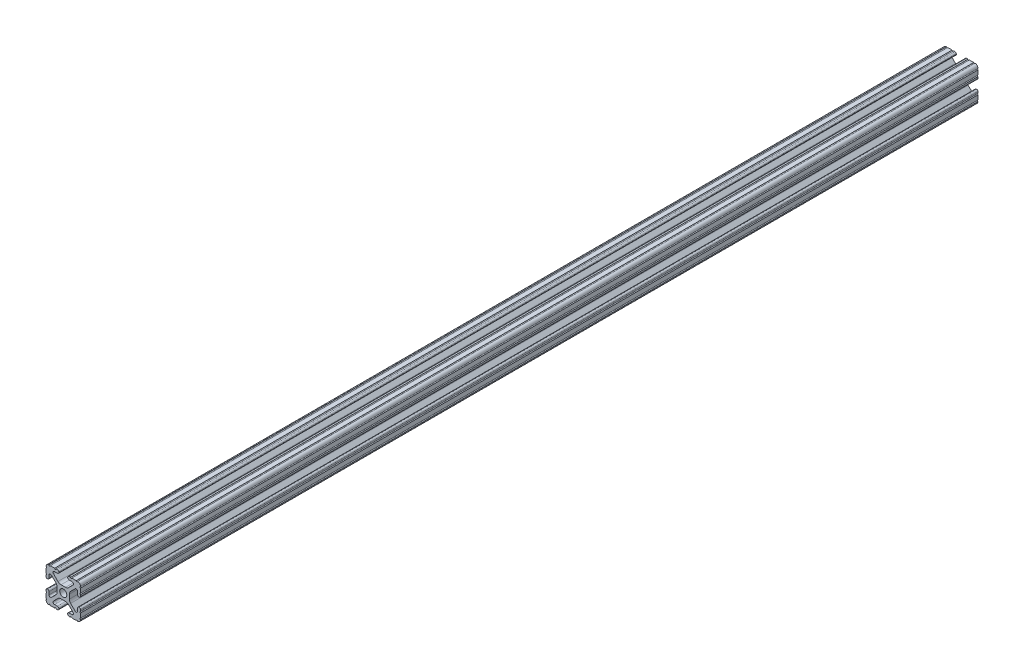
from build123d import *

# Parameters (mm, degrees)
SKETCH1_R               = 2.6035
BOSS_EXTRUDE1_DEPTH     = 457.2
CUT_EXTRUDE2_DEPTH      = 4.318
CUT_EXTRUDE2_DEPTH_BACK = 26.924


with BuildPart() as part:
    # Sketch1 → Boss-Extrude1 (new body, symmetric)
    with BuildSketch(Plane.XY):
        with BuildLine():
            Line((-7.179650497, -8.645192506), (-3.952270251, -5.423690499))
            ThreePointArc((-3.952270251, -5.423690499), (-2.922936451, -4.736929036), (-1.709253557, -4.4958))
            Line((-1.709253557, -4.4958), (1.709253557, -4.4958))
            ThreePointArc((1.709253557, -4.4958), (2.922936451, -4.736929036), (3.952270251, -5.423690499))
            Line((3.952270251, -5.423690499), (7.179650497, -8.645192506))
            ThreePointArc((7.179650497, -8.645192506), (7.41473083, -9.822813117), (6.416408329, -10.4902))
            Line((6.416408329, -10.4902), (4.287512407, -10.4902))
            ThreePointArc((4.287512407, -10.4902), (3.54574862, -10.79744862), (3.2385, -11.539212407))
            Line((3.2385, -11.539212407), (3.2385, -11.650987593))
            ThreePointArc((3.2385, -11.650987593), (3.54574862, -12.39275138), (4.287512407, -12.7))
            Line((4.287512407, -12.7), (5.317126718, -12.7))
            ThreePointArc((5.317126718, -12.7), (5.825126718, -12.192), (6.333126718, -12.7))
            Line((6.333126718, -12.7), (9.550443118, -12.7))
            ThreePointArc((9.550443118, -12.7), (10.058366869, -12.192000006), (10.566443095, -12.699847501))
            ThreePointArc((10.566443095, -12.699847501), (12.082537762, -12.08250727), (12.699846982, -10.566399977))
            ThreePointArc((12.699846982, -10.566399977), (12.192000006, -10.058323491), (12.7, -9.5504))
            Line((12.7, -9.5504), (12.7, -6.3330836))
            ThreePointArc((12.7, -6.3330836), (12.192, -5.8250836), (12.7, -5.3170836))
            Line((12.7, -5.3170836), (12.7, -4.287469289))
            ThreePointArc((12.7, -4.287469289), (12.39275138, -3.545705502), (11.650987593, -3.238456882))
            Line((11.650987593, -3.238456882), (11.539212407, -3.238456882))
            ThreePointArc((11.539212407, -3.238456882), (10.79744862, -3.545705502), (10.4902, -4.287469289))
            Line((10.4902, -4.287469289), (10.4902, -6.402089023))
            ThreePointArc((10.4902, -6.402089023), (9.856505071, -7.351067942), (8.737131347, -7.129408934))
            Line((8.737131347, -7.129408934), (5.441005833, -3.840816462))
            ThreePointArc((5.441005833, -3.840816462), (4.750877967, -2.809883091), (4.5085, -1.593185507))
            Line((4.5085, -1.593185507), (4.5085, 1.593185507))
            ThreePointArc((4.5085, 1.593185507), (4.750877967, 2.809883091), (5.441005833, 3.840816462))
            Line((5.441005833, 3.840816462), (8.737131347, 7.129408934))
            ThreePointArc((8.737131347, 7.129408934), (9.856505071, 7.351067942), (10.4902, 6.402089023))
            Line((10.4902, 6.402089023), (10.4902, 4.287469289))
            ThreePointArc((10.4902, 4.287469289), (10.79744862, 3.545705502), (11.539212407, 3.238456882))
            Line((11.539212407, 3.238456882), (11.650987593, 3.238456882))
            ThreePointArc((11.650987593, 3.238456882), (12.39275138, 3.545705502), (12.7, 4.287469289))
            Line((12.7, 4.287469289), (12.7, 5.3170836))
            ThreePointArc((12.7, 5.3170836), (12.192, 5.8250836), (12.7, 6.3330836))
            Line((12.7, 6.3330836), (12.7, 9.5504))
            ThreePointArc((12.7, 9.5504), (12.192000006, 10.058323491), (12.699846982, 10.566399977))
            ThreePointArc((12.699846982, 10.566399977), (12.082537762, 12.08250727), (10.566443095, 12.699847501))
            ThreePointArc((10.566443095, 12.699847501), (10.058366869, 12.192000006), (9.550443118, 12.7))
            Line((9.550443118, 12.7), (6.333126718, 12.7))
            ThreePointArc((6.333126718, 12.7), (5.825126718, 12.192), (5.317126718, 12.7))
            Line((5.317126718, 12.7), (4.287512407, 12.7))
            ThreePointArc((4.287512407, 12.7), (3.54574862, 12.39275138), (3.2385, 11.650987593))
            Line((3.2385, 11.650987593), (3.2385, 11.539212407))
            ThreePointArc((3.2385, 11.539212407), (3.54574862, 10.79744862), (4.287512407, 10.4902))
            Line((4.287512407, 10.4902), (6.476788598, 10.4902))
            ThreePointArc((6.476788598, 10.4902), (7.432222385, 9.85140422), (7.207036008, 8.724370562))
            Line((7.207036008, 8.724370562), (3.898272566, 5.423169045))
            ThreePointArc((3.898272566, 5.423169045), (2.869120213, 4.736787962), (1.655778399, 4.4958))
            Line((1.655778399, 4.4958), (-1.655778399, 4.4958))
            ThreePointArc((-1.655778399, 4.4958), (-2.869120213, 4.736787962), (-3.898272566, 5.423169045))
            Line((-3.898272566, 5.423169045), (-7.207036008, 8.724370562))
            ThreePointArc((-7.207036008, 8.724370562), (-7.432222385, 9.85140422), (-6.476788598, 10.4902))
            Line((-6.476788598, 10.4902), (-4.287512407, 10.4902))
            ThreePointArc((-4.287512407, 10.4902), (-3.54574862, 10.79744862), (-3.2385, 11.539212407))
            Line((-3.2385, 11.539212407), (-3.2385, 11.650987593))
            ThreePointArc((-3.2385, 11.650987593), (-3.54574862, 12.39275138), (-4.287512407, 12.7))
            Line((-4.287512407, 12.7), (-5.317126718, 12.7))
            ThreePointArc((-5.317126718, 12.7), (-5.825126718, 12.192), (-6.333126718, 12.7))
            Line((-6.333126718, 12.7), (-9.550443118, 12.7))
            ThreePointArc((-9.550443118, 12.7), (-10.058366869, 12.192000006), (-10.566443095, 12.699847501))
            ThreePointArc((-10.566443095, 12.699847501), (-12.082537762, 12.08250727), (-12.699846982, 10.566399977))
            ThreePointArc((-12.699846982, 10.566399977), (-12.192000006, 10.058323491), (-12.7, 9.5504))
            Line((-12.7, 9.5504), (-12.7, 6.3330836))
            ThreePointArc((-12.7, 6.3330836), (-12.192, 5.8250836), (-12.7, 5.3170836))
            Line((-12.7, 5.3170836), (-12.7, 4.287469289))
            ThreePointArc((-12.7, 4.287469289), (-12.39275138, 3.545705502), (-11.650987593, 3.238456882))
            Line((-11.650987593, 3.238456882), (-11.539212407, 3.238456882))
            ThreePointArc((-11.539212407, 3.238456882), (-10.79744862, 3.545705502), (-10.4902, 4.287469289))
            Line((-10.4902, 4.287469289), (-10.4902, 6.402089023))
            ThreePointArc((-10.4902, 6.402089023), (-9.856505071, 7.351067942), (-8.737131347, 7.129408934))
            Line((-8.737131347, 7.129408934), (-5.441005833, 3.840816462))
            ThreePointArc((-5.441005833, 3.840816462), (-4.750877967, 2.809883091), (-4.5085, 1.593185507))
            Line((-4.5085, 1.593185507), (-4.5085, -1.593185507))
            ThreePointArc((-4.5085, -1.593185507), (-4.750877967, -2.809883091), (-5.441005833, -3.840816462))
            Line((-5.441005833, -3.840816462), (-8.737131347, -7.129408934))
            ThreePointArc((-8.737131347, -7.129408934), (-9.856505071, -7.351067942), (-10.4902, -6.402089023))
            Line((-10.4902, -6.402089023), (-10.4902, -4.287469289))
            ThreePointArc((-10.4902, -4.287469289), (-10.79744862, -3.545705502), (-11.539212407, -3.238456882))
            Line((-11.539212407, -3.238456882), (-11.650987593, -3.238456882))
            ThreePointArc((-11.650987593, -3.238456882), (-12.39275138, -3.545705502), (-12.7, -4.287469289))
            Line((-12.7, -4.287469289), (-12.7, -5.3170836))
            ThreePointArc((-12.7, -5.3170836), (-12.192, -5.8250836), (-12.7, -6.3330836))
            Line((-12.7, -6.3330836), (-12.7, -9.5504))
            ThreePointArc((-12.7, -9.5504), (-12.192000006, -10.058323491), (-12.699846982, -10.566399977))
            ThreePointArc((-12.699846982, -10.566399977), (-12.082537762, -12.08250727), (-10.566443095, -12.699847501))
            ThreePointArc((-10.566443095, -12.699847501), (-10.058366869, -12.192000006), (-9.550443118, -12.7))
            Line((-9.550443118, -12.7), (-6.333126718, -12.7))
            ThreePointArc((-6.333126718, -12.7), (-5.825126718, -12.192), (-5.317126718, -12.7))
            Line((-5.317126718, -12.7), (-4.287512407, -12.7))
            ThreePointArc((-4.287512407, -12.7), (-3.54574862, -12.39275138), (-3.2385, -11.650987593))
            Line((-3.2385, -11.650987593), (-3.2385, -11.539212407))
            ThreePointArc((-3.2385, -11.539212407), (-3.54574862, -10.79744862), (-4.287512407, -10.4902))
            Line((-4.287512407, -10.4902), (-6.416408329, -10.4902))
            ThreePointArc((-6.416408329, -10.4902), (-7.41473083, -9.822813117), (-7.179650497, -8.645192506))
        make_face()
        Circle(SKETCH1_R, mode=Mode.SUBTRACT)
    extrude(amount=BOSS_EXTRUDE1_DEPTH, both=True)

    # Sketch3 → Cut-Extrude2 (cut, two sides)
    with BuildSketch(Plane.ZY.offset(12.7)) as cut_extrude2_sk:
        Polygon((-203.2, -27.552777595), (-203.2, 21.158109763), (-461.090893327, 21.158109763), (-461.090893327, -25.4), align=None)
    extrude(amount=CUT_EXTRUDE2_DEPTH, mode=Mode.SUBTRACT)
    extrude(cut_extrude2_sk.sketch, amount=-CUT_EXTRUDE2_DEPTH_BACK, mode=Mode.SUBTRACT)


solid = part.part
